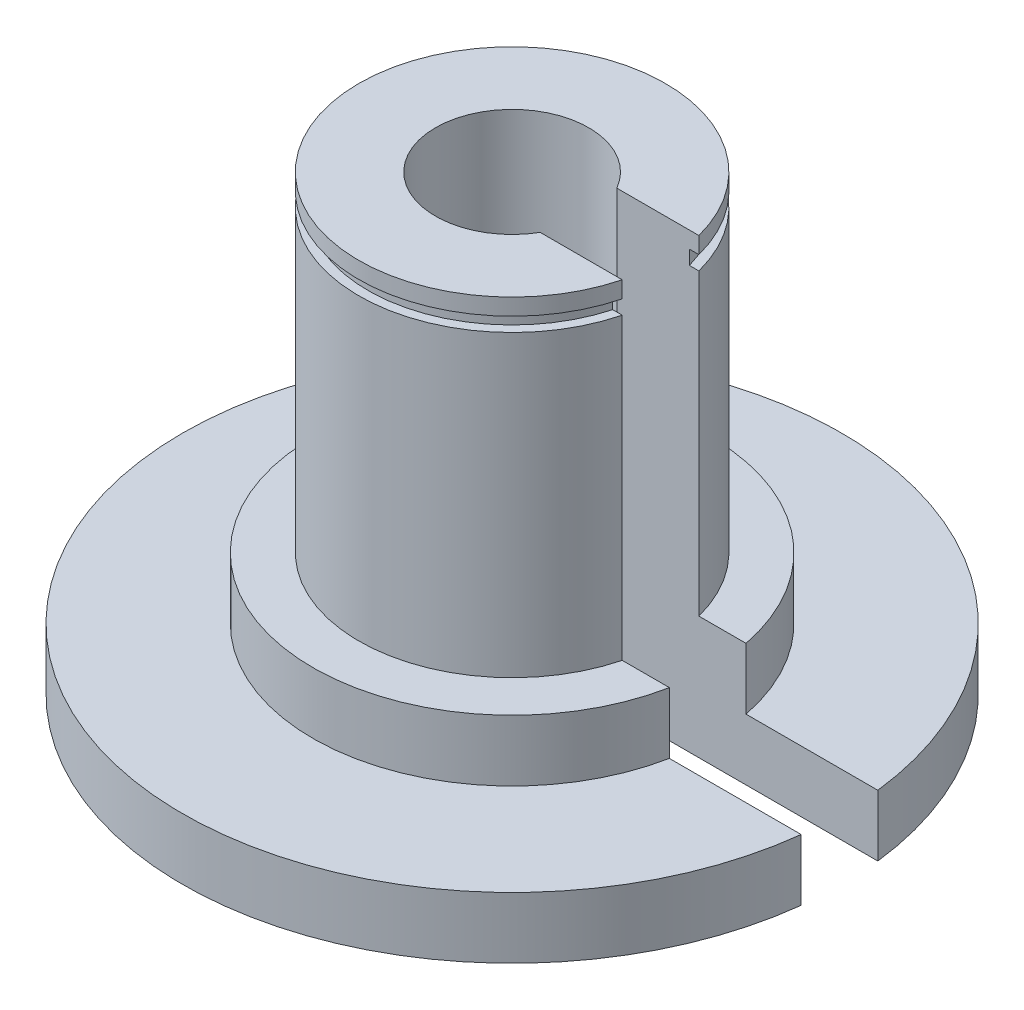
from build123d import *

# Parameters (mm, degrees)
SKETCH1_R           = 27.305
SKETCH1_R_2         = 4.5466
BOSS_EXTRUDE1_DEPTH = 50.8
SKETCH2_R           = 6.35
CUT_EXTRUDE1_DEPTH  = 44.45
SKETCH3_OUTSIDE_W   = 75.098
SKETCH3_OUTSIDE_H   = 75.098
SKETCH3_OUTSIDE_R   = 12.7
CUT_EXTRUDE2_DEPTH  = 44.45
SKETCH10_W          = 30.679481275
SKETCH10_H          = 6.35
CUT_EXTRUDE7_DEPTH  = 6.35
SKETCH13_OUTSIDE_W  = 74.891
SKETCH13_OUTSIDE_H  = 75.076
SKETCH13_OUTSIDE_R  = 11.938
CUT_EXTRUDE9_DEPTH  = 1.1684
SKETCH16_R          = 46.08237905
CUT_EXTRUDE11_DEPTH = 54.802902106
BOSS_EXTRUDE4_START = 3.81
SKETCH18_R          = 16.51
SKETCH18_R_2        = 12.7
BOSS_EXTRUDE4_DEPTH = 3.81
SKETCH19_OUTSIDE_W  = 73.569
SKETCH19_OUTSIDE_H  = 73.754
SKETCH19_OUTSIDE_R  = 16.51
CUT_EXTRUDE12_DEPTH = 1.27
SKETCH10_2_W        = 30.679481275
SKETCH10_2_H        = 6.35
CUT_EXTRUDE13_DEPTH = 54.802902106


with BuildPart() as part:
    # Sketch1 → Boss-Extrude1 (new body)
    with BuildSketch(Plane(origin=(0, 0, 0), x_dir=(1, 0, 0), z_dir=(0, 1, 0))):
        Circle(SKETCH1_R)
        Circle(SKETCH1_R_2, mode=Mode.SUBTRACT)
    extrude(amount=BOSS_EXTRUDE1_DEPTH)

    # Sketch2 → Cut-Extrude1 (cut)
    with BuildSketch(Plane(origin=(0, 50.8, 0), x_dir=(1, 0, 0), z_dir=(0, 1, 0))):
        Circle(SKETCH2_R)
    extrude(amount=-CUT_EXTRUDE1_DEPTH, mode=Mode.SUBTRACT)

    # Sketch3 outside → Cut-Extrude2 (cut)
    with BuildSketch(Plane(origin=(0, 50.8, 0), x_dir=(1, 0, 0), z_dir=(0, 1, 0))):
        Rectangle(SKETCH3_OUTSIDE_W, SKETCH3_OUTSIDE_H)
        Circle(SKETCH3_OUTSIDE_R, mode=Mode.SUBTRACT)
    extrude(amount=-CUT_EXTRUDE2_DEPTH, mode=Mode.SUBTRACT)

    # Sketch10 → Cut-Extrude7 (cut)
    with BuildSketch(Plane.XZ):
        with Locations((17.839550223, 0)):
            Rectangle(SKETCH10_W, SKETCH10_H)
    extrude(amount=-CUT_EXTRUDE7_DEPTH, mode=Mode.SUBTRACT)

    # Sketch13 outside → Cut-Extrude9 (cut)
    with BuildSketch(Plane(origin=(0, 34.925, 0), x_dir=(-1, 0, 0), z_dir=(0, 1, 0))):
        with Locations((0.0925, 0)):
            Rectangle(SKETCH13_OUTSIDE_W, SKETCH13_OUTSIDE_H)
        Circle(SKETCH13_OUTSIDE_R, mode=Mode.SUBTRACT)
    extrude(amount=CUT_EXTRUDE9_DEPTH, mode=Mode.SUBTRACT)

    # Sketch16 → Cut-Extrude11 (cut, through all)
    with BuildSketch(Plane(origin=(0, 37.465, 0), x_dir=(-1, 0, 0), z_dir=(0, 1, 0))):
        Circle(SKETCH16_R)
    extrude(amount=CUT_EXTRUDE11_DEPTH, mode=Mode.SUBTRACT)

    # Sketch18 → Boss-Extrude4 (add)
    with BuildSketch(Plane(origin=(0, 6.35, 0), x_dir=(1, 0, 0), z_dir=(0, 1, 0)).offset(BOSS_EXTRUDE4_START)):
        Circle(SKETCH18_R)
        Circle(SKETCH18_R_2, mode=Mode.SUBTRACT)
    extrude(amount=-BOSS_EXTRUDE4_DEPTH)

    # Sketch19 outside → Cut-Extrude12 (cut)
    with BuildSketch(Plane(origin=(0, 6.35, 0), x_dir=(1, 0, 0), z_dir=(0, 1, 0))):
        with Locations((-0.0925, 0)):
            Rectangle(SKETCH19_OUTSIDE_W, SKETCH19_OUTSIDE_H)
        Circle(SKETCH19_OUTSIDE_R, mode=Mode.SUBTRACT)
    extrude(amount=-CUT_EXTRUDE12_DEPTH, mode=Mode.SUBTRACT)

    # Sketch10_2 → Cut-Extrude13 (cut, through all)
    with BuildSketch(Plane.XZ):
        with Locations((17.839550223, 0)):
            Rectangle(SKETCH10_2_W, SKETCH10_2_H)
    extrude(amount=-CUT_EXTRUDE13_DEPTH, mode=Mode.SUBTRACT)


solid = part.part
